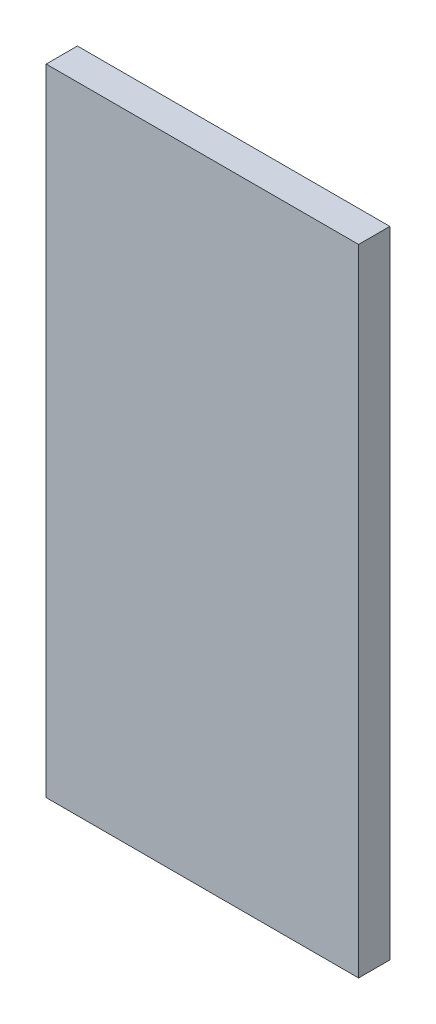
from build123d import *

# Parameters (mm, degrees)
MODEL_W             = 30
MODEL_H             = 61
BOSS_EXTRUDE1_DEPTH = 3


with BuildPart() as part:
    # Model → Boss-Extrude1 (new body)
    with BuildSketch(Plane.XY):
        with Locations((-110.350427846, 74.490843821)):
            Rectangle(MODEL_W, MODEL_H)
    extrude(amount=BOSS_EXTRUDE1_DEPTH)


solid = part.part
